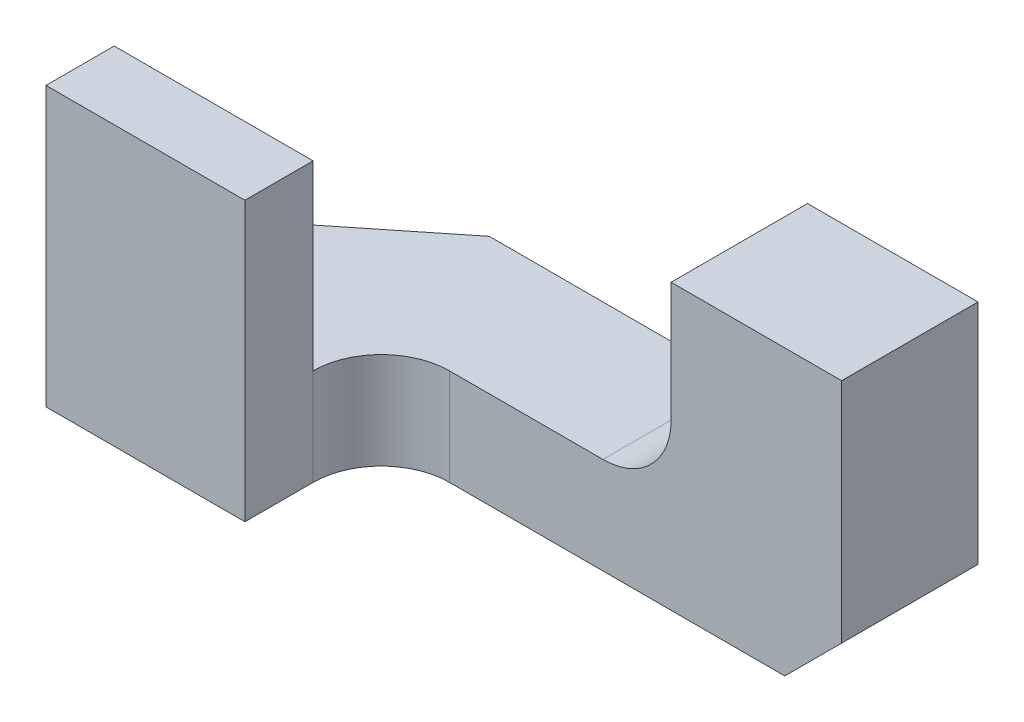
from build123d import *

# Parameters (mm, degrees)
SKETCH1_W           = 14.732
SKETCH1_H           = 6.096
BOSS_EXTRUDE1_DEPTH = 6.35
CUT_EXTRUDE2_DEPTH  = 7.35
SKETCH3_W           = 10.922
SKETCH3_H           = 6.096
CUT_EXTRUDE1_DEPTH  = 2.667
CUT_EXTRUDE3_DEPTH  = 4.683
SKETCH9_W           = 4.445
SKETCH9_H           = 1.524
BOSS_EXTRUDE2_DEPTH = 2.54
CUT_EXTRUDE4_DEPTH  = 7.096
CUT_EXTRUDE5_DEPTH  = 4.191
SKETCH15_W          = 0.048393345
SKETCH15_H          = 1.524
CUT_EXTRUDE10_DEPTH = 2.905
SKETCH13_W          = 4.445
SKETCH13_H          = 1.524
CUT_EXTRUDE11_DEPTH = 4.572


with BuildPart() as part:
    # Sketch1 → Boss-Extrude1 (new body)
    with BuildSketch(Plane(origin=(0, 0, 0), x_dir=(1, 0, 0), z_dir=(0, 1, 0))):
        Rectangle(SKETCH1_W, SKETCH1_H)
    extrude(amount=BOSS_EXTRUDE1_DEPTH)

    # Sketch4 → Cut-Extrude2 (cut, through all)
    with BuildSketch(Plane(origin=(0, 6.35, 0), x_dir=(1, 0, 0), z_dir=(0, 1, 0))):
        with BuildLine():
            Line((7.366, 0), (-1.397, 0))
            ThreePointArc((-1.397, 0), (-0.319369265, -0.446369265), (0.127, -1.524))
            ThreePointArc((0.127, -1.524), (-0.319369265, -2.601630735), (-1.397, -3.048))
            Line((-1.397, -3.048), (7.366, -3.048))
            Line((7.366, -3.048), (7.366, 0))
        make_face()
        with BuildLine():
            ThreePointArc((0.127, -1.524), (-0.319369265, -0.446369265), (-1.397, 0))
            Line((-1.397, 0), (-1.397, -3.048))
            ThreePointArc((-1.397, -3.048), (-0.319369265, -2.601630735), (0.127, -1.524))
        make_face()
        with BuildLine():
            Line((-1.397, -3.048), (-1.397, 0))
            ThreePointArc((-1.397, 0), (-2.474630735, -0.446369265), (-2.921, -1.524))
            ThreePointArc((-2.921, -1.524), (-2.474630735, -2.601630735), (-1.397, -3.048))
        make_face()
        with BuildLine():
            ThreePointArc((-1.397, -3.048), (-2.474630735, -2.601630735), (-2.921, -1.524))
            Line((-2.921, -1.524), (-2.921, -3.048))
            Line((-2.921, -3.048), (-1.397, -3.048))
        make_face()
    extrude(amount=-CUT_EXTRUDE2_DEPTH, mode=Mode.SUBTRACT)

    # Sketch3 → Cut-Extrude1 (cut)
    with BuildSketch(Plane(origin=(0, 6.35, 0), x_dir=(1, 0, 0), z_dir=(0, 1, 0))):
        with Locations((-1.905, 0)):
            Rectangle(SKETCH3_W, SKETCH3_H)
    extrude(amount=-CUT_EXTRUDE1_DEPTH, mode=Mode.SUBTRACT)

    # Sketch8 → Cut-Extrude3 (cut, through all)
    with BuildSketch(Plane(origin=(0, 3.683, 0), x_dir=(1, 0, 0), z_dir=(0, 1, 0))):
        Polygon((-7.366, 0), (-3.556, 3.048), (-7.366, 3.048), align=None)
    extrude(amount=-CUT_EXTRUDE3_DEPTH, mode=Mode.SUBTRACT)

    # Sketch9 → Boss-Extrude2 (add)
    with BuildSketch(Plane(origin=(0, 3.683, 0), x_dir=(1, 0, 0), z_dir=(0, 1, 0))):
        with Locations((-5.1435, -2.286)):
            Rectangle(SKETCH9_W, SKETCH9_H)
    extrude(amount=BOSS_EXTRUDE2_DEPTH)

    # Sketch10 → Cut-Extrude4 (cut, through all)
    with BuildSketch(Plane(origin=(0, 0, -3.048), x_dir=(-1, 0, 0), z_dir=(0, 0, -1))):
        Polygon((-7.366, 1.27), (-6.096, 0), (-7.366, 0), align=None)
    extrude(amount=-CUT_EXTRUDE4_DEPTH, mode=Mode.SUBTRACT)

    # Sketch12 → Cut-Extrude5 (cut)
    with BuildSketch(Plane(origin=(0, 0, -3.048), x_dir=(-1, 0, 0), z_dir=(0, 0, -1))):
        with BuildLine():
            ThreePointArc((-3.556, 3.683), (-3.109630735, 2.605369265), (-2.032, 2.159))
            Line((-2.032, 2.159), (2.921, 2.159))
            Line((2.921, 2.159), (2.921, 3.683))
            Line((2.921, 3.683), (-3.556, 3.683))
        make_face()
    extrude(amount=-CUT_EXTRUDE5_DEPTH, mode=Mode.SUBTRACT)

    # Sketch15 → Cut-Extrude10 (cut, through all)
    with BuildSketch(Plane(origin=(0, 0, 1.143), x_dir=(-1, 0, 0), z_dir=(0, 0, -1))):
        with Locations((2.896803328, 2.921)):
            Rectangle(SKETCH15_W, SKETCH15_H)
    extrude(amount=-CUT_EXTRUDE10_DEPTH, mode=Mode.SUBTRACT)

    # Sketch13 → Cut-Extrude11 (cut)
    with BuildSketch(Plane(origin=(0, 0, -3.048), x_dir=(-1, 0, 0), z_dir=(0, 0, -1))):
        with Locations((5.1435, 2.921)):
            Rectangle(SKETCH13_W, SKETCH13_H)
    extrude(amount=-CUT_EXTRUDE11_DEPTH, mode=Mode.SUBTRACT)


solid = part.part
